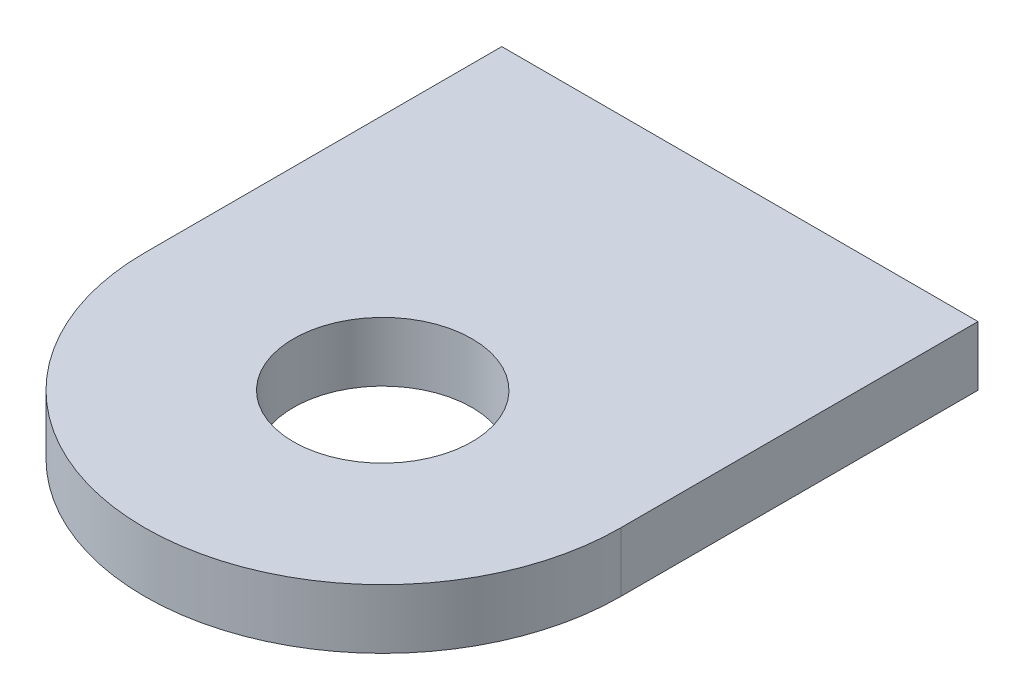
from build123d import *

# Parameters (mm, degrees)
SKETCH1_R           = 9.525
BOSS_EXTRUDE1_DEPTH = 3.175


with BuildPart() as part:
    # Sketch1 → Boss-Extrude1 (new body, symmetric)
    with BuildSketch(Plane(origin=(0, 0, 0), x_dir=(1, 0, 0), z_dir=(0, 1, 0))):
        with BuildLine():
            Line((-25.4, 0), (-25.4, -38.1))
            ThreePointArc((-25.4, -38.1), (0, -63.5), (25.4, -38.1))
            Line((25.4, -38.1), (25.4, 0))
            Line((25.4, 0), (-25.4, 0))
        make_face()
        with Locations((0, -38.1)):
            Circle(SKETCH1_R, mode=Mode.SUBTRACT)
    extrude(amount=BOSS_EXTRUDE1_DEPTH, both=True)


solid = part.part
